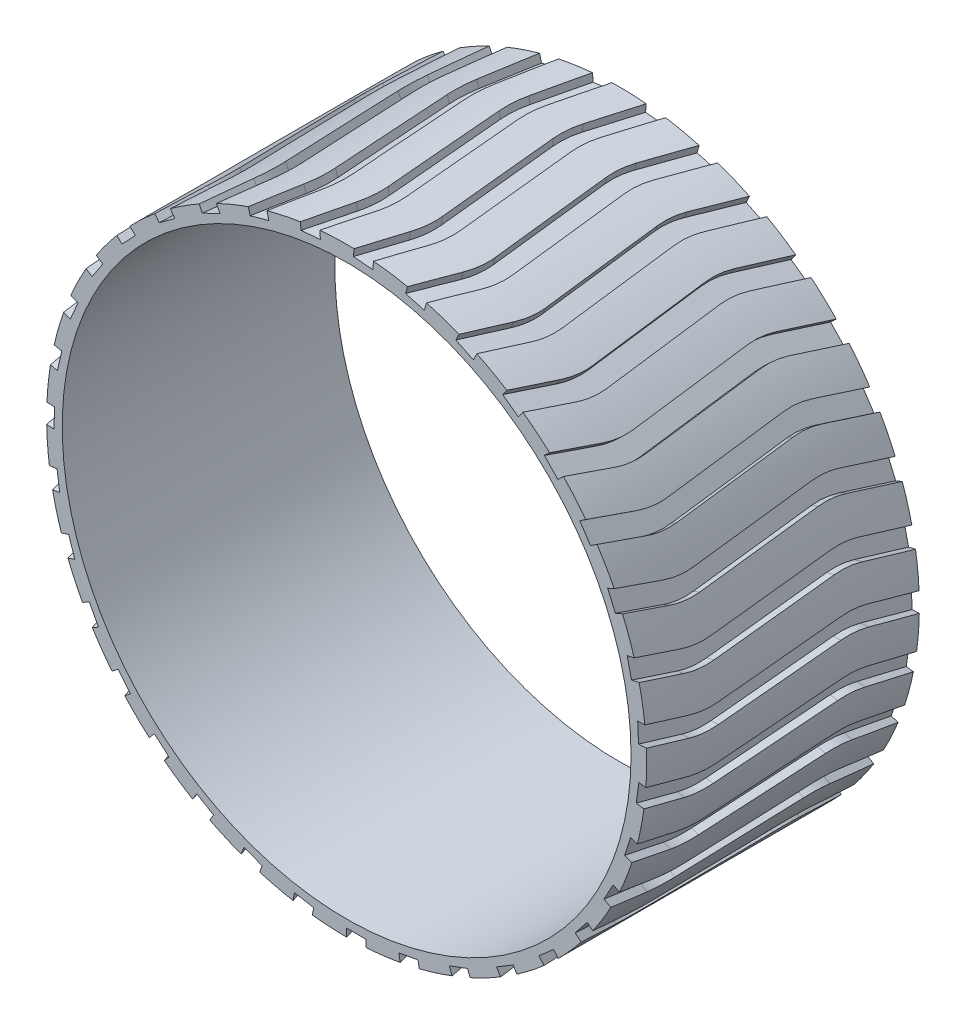
from build123d import *

# Parameters (mm, degrees)
SKETCH1_R           = 77
SKETCH1_R_2         = 73
BOSS_EXTRUDE1_DEPTH = 70
CUT_EXTRUDE2_START  = -75
CUT_EXTRUDE2_DEPTH  = 5
CIRPATTERN1_COUNT   = 35


with BuildPart() as part:
    # Sketch1 → Boss-Extrude1 (new body)
    with BuildSketch(Plane.XY):
        Circle(SKETCH1_R)
        Circle(SKETCH1_R_2, mode=Mode.SUBTRACT)
    extrude(amount=BOSS_EXTRUDE1_DEPTH)

    # Sketch3 → Cut-Extrude2 (cut)
    with BuildSketch(Plane(origin=(0, 0, 0), x_dir=(1, 0, 0), z_dir=(0, 1, 0)).offset(CUT_EXTRUDE2_START)):
        with BuildLine():
            Line((0, 0), (-5, 0))
            Line((-5, 0), (-1.516285962, -13.065767489))
            ThreePointArc((-1.516285962, -13.065767489), (-0.91043708, -16.555192838), (-0.929573095, -20.09677101))
            Line((-0.929573095, -20.09677101), (-3.900263922, -51.586497948))
            ThreePointArc((-3.900263922, -51.586497948), (-3.898799409, -55.358813792), (-3.189013733, -59.063752829))
            Line((-3.189013733, -59.063752829), (0, -70))
            Line((0, -70), (5, -70))
            Line((5, -70), (1.74312847, -58.831044631))
            ThreePointArc((1.74312847, -58.831044631), (1.033342794, -55.126105594), (1.031878281, -51.35378975))
            Line((1.031878281, -51.35378975), (4.00408781, -19.847964367))
            ThreePointArc((4.00408781, -19.847964367), (4.023223824, -16.306386195), (3.417374943, -12.816960845))
            Line((3.417374943, -12.816960845), (0, 0))
        make_face()
    cut_extrude2 = extrude(amount=-CUT_EXTRUDE2_DEPTH, mode=Mode.SUBTRACT)

    # CirPattern1: Cut-Extrude2 ×35 about axis
    cirpattern1_axis = Axis((0, 0, 0), (0, 0, 1))
    for i in range(1, CIRPATTERN1_COUNT):
        add(cut_extrude2.rotate(cirpattern1_axis, i * 360 / CIRPATTERN1_COUNT), mode=Mode.SUBTRACT)


solid = part.part
